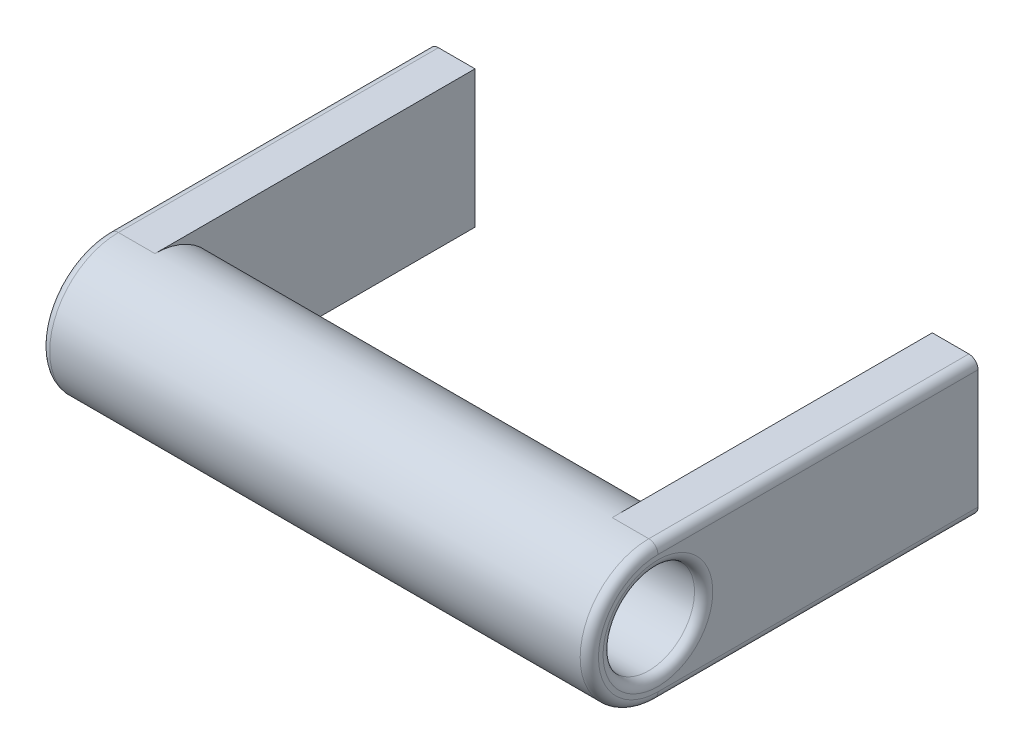
from build123d import *

# Parameters (mm, degrees)
SKETCH1_W                      = 10
SKETCH1_H                      = 30
BOSS_EXTRUDE1_DEPTH            = 70
BOSS_EXTRUDE1_2_DEPTH          = 70
SKETCH2_R                      = 15
BOSS_EXTRUDE2_DEPTH            = 120
CUT_EXTRUDE1_REACH             = 122
SKETCH3_R                      = 10
CUT_EXTRUDE1_DIRECTION_2_DEPTH = 1
FILLET1_R                      = 2
SKETCH4_R                      = 1.5
CUT_EXTRUDE2_DEPTH             = 15


with BuildPart() as part:
    # Sketch1 → Boss-Extrude1 (new body)
    with BuildSketch(Plane.XY):
        with Locations((55, 0)):
            Rectangle(SKETCH1_W, SKETCH1_H)
    extrude(amount=BOSS_EXTRUDE1_DEPTH)



with BuildPart() as body_2:
    # Sketch1 → Boss-Extrude1 2 (new body)
    with BuildSketch(Plane.XY):
        with Locations((-55, 0)):
            Rectangle(SKETCH1_W, SKETCH1_H)
    extrude(amount=BOSS_EXTRUDE1_2_DEPTH)


with BuildPart() as part_1:
    add(part.part)

    add(body_2.part)  # Boss-Extrude2 merges body 2
    # Sketch2 → Boss-Extrude2 (add)
    with BuildSketch(Plane(origin=(60, 0, 0), x_dir=(0, 0, -1), z_dir=(1, 0, 0))):
        with Locations((-70, 0)):
            Circle(SKETCH2_R)
    extrude(amount=-BOSS_EXTRUDE2_DEPTH)

    # Sketch3 → Cut-Extrude1 (cut, up to next)
    with BuildSketch(Plane.ZY.offset(60), mode=Mode.PRIVATE) as cut_extrude1_sk1:
        with Locations((70, 0)):
            Circle(SKETCH3_R)
    cut_extrude1_tool1 = extrude(cut_extrude1_sk1.sketch, amount=-CUT_EXTRUDE1_REACH, mode=Mode.PRIVATE) & part_1.part
    add(cut_extrude1_tool1.solids().sort_by_distance((-60, 0, 70))[0], mode=Mode.SUBTRACT)

    # Sketch3 → Cut-Extrude1 direction 2 (cut)
    with BuildSketch(Plane.ZY.offset(60)):
        with Locations((70, 0)):
            Circle(SKETCH3_R)
    extrude(amount=CUT_EXTRUDE1_DIRECTION_2_DEPTH, mode=Mode.SUBTRACT)

    # Fillet1
    fillet1_edges = [part_1.edges().sort_by_distance(p)[0] for p in [
        (60, 0, 85),
        (-60, 0, 85),
        (-60, 15, 35),
        (-60, -15, 35),
        (-60, 0, 60),
        (60, 0, 60),
        (60, 15, 35),
        (60, -15, 35),
    ]]
    fillet(fillet1_edges, radius=FILLET1_R)

    # Sketch4 → Cut-Extrude2 (cut)
    with BuildSketch(Plane(origin=(0, 0, 0), x_dir=(-1, 0, 0), z_dir=(0, 0, -1))):
        with Locations((-55, 7)):
            Circle(SKETCH4_R)
        with Locations((-55, -7)):
            Circle(SKETCH4_R)
        with Locations((55, -7)):
            Circle(SKETCH4_R)
        with Locations((55, 7)):
            Circle(SKETCH4_R)
    extrude(amount=-CUT_EXTRUDE2_DEPTH, mode=Mode.SUBTRACT)


solid = part_1.part
